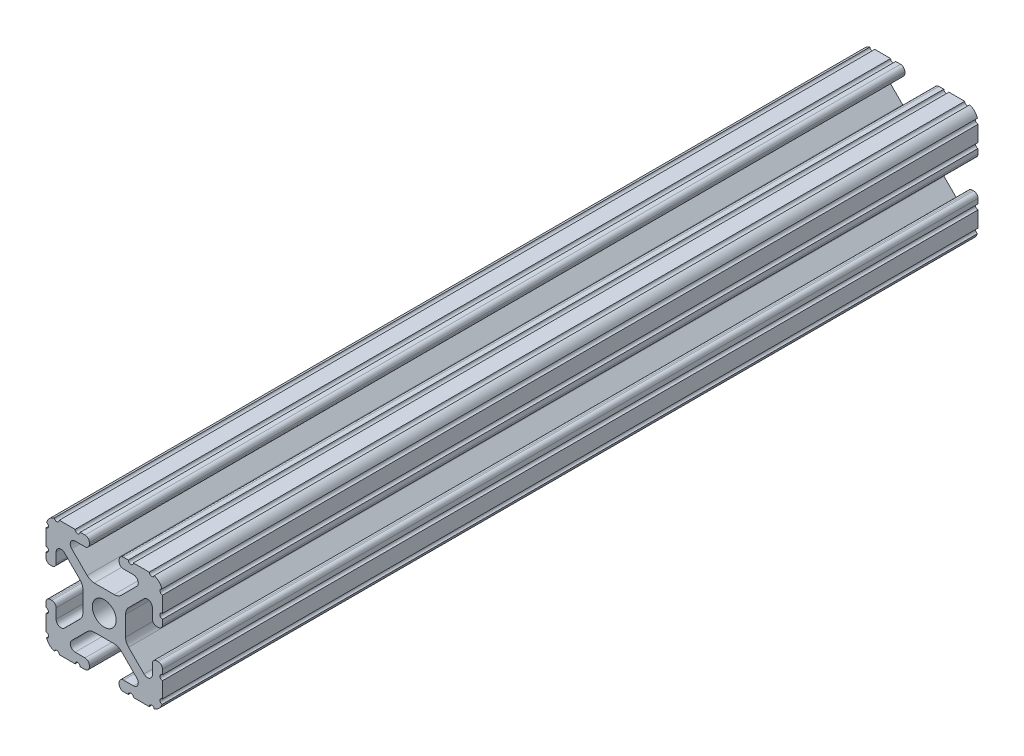
from build123d import *

# Parameters (mm, degrees)
BOSS_EXTRUDE1_DEPTH     = 88.9
SKETCH5_R               = 0.55245
CUT_EXTRUDE1_DEPTH      = 89.9
CUT_EXTRUDE1_DEPTH_BACK = 89.9


with BuildPart() as part:
    # Sketch4 → Boss-Extrude1 (new body, symmetric)
    with BuildSketch(Plane.XY):
        with BuildLine():
            Line((4.190365, -12.7), (10.11729625, -12.7))
            ThreePointArc((10.11729625, -12.7), (11.943543585, -11.943543585), (12.7, -10.11729625))
            Line((12.7, -10.11729625), (12.7, -4.190365))
            ThreePointArc((12.7, -4.190365), (12.42492494, -3.52627506), (11.760835, -3.2512))
            Line((11.760835, -3.2512), (11.429365, -3.2512))
            ThreePointArc((11.429365, -3.2512), (10.76527506, -3.52627506), (10.4902, -4.190365))
            Line((10.4902, -4.190365), (10.4902, -6.348478019))
            ThreePointArc((10.4902, -6.348478019), (9.830707141, -7.335478831), (8.666460301, -7.103895736))
            Line((8.666460301, -7.103895736), (5.299899128, -3.737334563))
            ThreePointArc((5.299899128, -3.737334563), (4.817571085, -3.015479634), (4.6482, -2.16399369))
            Line((4.6482, -2.16399369), (4.6482, 0))
            Line((4.6482, 0), (2.6035, 0))
            ThreePointArc((2.6035, 0), (1.840952505, -1.840952505), (0, -2.6035))
            Line((0, -2.6035), (0, -4.6482))
            Line((0, -4.6482), (2.16399369, -4.6482))
            ThreePointArc((2.16399369, -4.6482), (3.015479634, -4.817571085), (3.737334563, -5.299899128))
            Line((3.737334563, -5.299899128), (7.103895736, -8.666460301))
            ThreePointArc((7.103895736, -8.666460301), (7.335478831, -9.830707141), (6.348478019, -10.4902))
            Line((6.348478019, -10.4902), (4.190365, -10.4902))
            ThreePointArc((4.190365, -10.4902), (3.52627506, -10.76527506), (3.2512, -11.429365))
            Line((3.2512, -11.429365), (3.2512, -11.760835))
            ThreePointArc((3.2512, -11.760835), (3.52627506, -12.42492494), (4.190365, -12.7))
        make_face()
    extrude(amount=BOSS_EXTRUDE1_DEPTH, both=True)

    # Sketch5 → Cut-Extrude1 (cut, two sides)
    with BuildSketch(Plane.XY) as cut_extrude1_sk:
        with Locations((10.356153152, -12.7)):
            Circle(SKETCH5_R)
        with Locations((5.796028019, -12.7)):
            Circle(SKETCH5_R)
        with Locations((12.7, -10.356153152)):
            Circle(SKETCH5_R)
        with Locations((12.7, -5.796028019)):
            Circle(SKETCH5_R)
    extrude(amount=CUT_EXTRUDE1_DEPTH, mode=Mode.SUBTRACT)
    extrude(cut_extrude1_sk.sketch, amount=-CUT_EXTRUDE1_DEPTH_BACK, mode=Mode.SUBTRACT)

    # Mirror1: part across plane


with BuildPart() as part_1:
    add(part.part)
    add(part.part.mirror(Plane(origin=(0, 0, 0), x_dir=(0, 0, 1), z_dir=(1, 0, 0))))

    # Mirror2: part across plane


with BuildPart() as part_2:
    add(part_1.part)
    add(part_1.part.mirror(Plane.ZX))


solid = part_2.part
